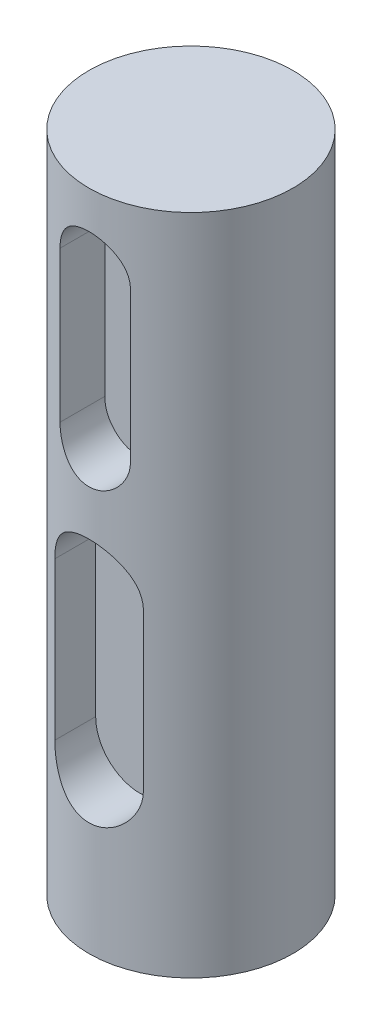
from build123d import *

# Parameters (mm, degrees)
SKETCH_2_R          = 10
EXTRUDE_1_DEPTH     = 65
CUT_EXTRUDE_2_DEPTH = 5
CUT_EXTRUDE_3_DEPTH = 5


with BuildPart() as part:
    # 草图2 → 凸台-拉伸1 (new body)
    with BuildSketch(Plane(origin=(0, 10, 0), x_dir=(1, 0, 0), z_dir=(0, 1, 0))):
        Circle(SKETCH_2_R)
    extrude(amount=EXTRUDE_1_DEPTH)

    # 草图5 → 切除-拉伸2 (cut)
    with BuildSketch(Plane.XY.offset(10)):
        with BuildLine():
            Line((4.341808906, 40.859733082), (4.341808906, 25.456649106))
            ThreePointArc((4.341808906, 25.456649106), (0, 21.114840199), (-4.341808906, 25.456649106))
            Line((-4.341808906, 25.456649106), (-4.341808906, 40.859733082))
            ThreePointArc((-4.341808906, 40.859733082), (0, 45.201541988), (4.341808906, 40.859733082))
        make_face()
    extrude(amount=-CUT_EXTRUDE_2_DEPTH, mode=Mode.SUBTRACT)

    # 草图6 → 切除-拉伸3 (cut)
    with BuildSketch(Plane.XY.offset(10)):
        with BuildLine():
            Line((3.451393492, 67.868636429), (3.451393492, 53.092358039))
            ThreePointArc((3.451393492, 53.092358039), (0, 49.640964547), (-3.451393492, 53.092358039))
            Line((-3.451393492, 53.092358039), (-3.451393492, 67.868636429))
            ThreePointArc((-3.451393492, 67.868636429), (0, 71.320029921), (3.451393492, 67.868636429))
        make_face()
    extrude(amount=-CUT_EXTRUDE_3_DEPTH, mode=Mode.SUBTRACT)


solid = part.part
